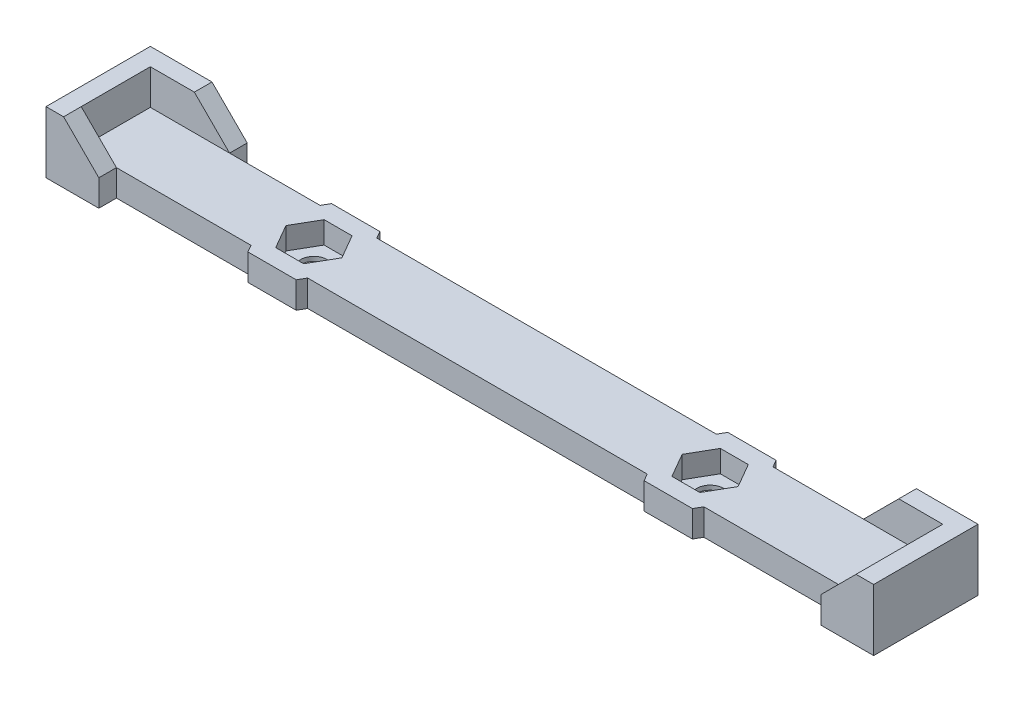
from build123d import *

# Parameters (mm, degrees)
SKETCH_1_W          = 90
SKETCH_1_H          = 7.85
EXTRUDE_1_DEPTH     = 2
SKETCH_2_W          = 7.85
SKETCH_2_H          = 6
EXTRUDE_2_DEPTH     = 2
SKETCH_3_W          = 7.85
SKETCH_3_H          = 6
EXTRUDE_3_DEPTH     = 2
EXTRUDE_4_DEPTH     = 2
EXTRUDE_5_DEPTH     = 2
EXTRUDE_8_DEPTH     = 1
CUT_EXTRUDE_1_DEPTH = 2.5
EXTRUDE_9_DEPTH     = 3
SKETCH_15_R         = 1.5
CUT_EXTRUDE_2_DEPTH = 3
SKETCH_16_R         = 1.5
CUT_EXTRUDE_3_DEPTH = 3


with BuildPart() as part:
    # 草图1 → 凸台-拉伸1 (new body)
    with BuildSketch(Plane(origin=(0, 0, 0), x_dir=(1, 0, 0), z_dir=(0, 1, 0))):
        with Locations((45, -3.925)):
            Rectangle(SKETCH_1_W, SKETCH_1_H)
    extrude(amount=EXTRUDE_1_DEPTH)

    # 草图2 → 凸台-拉伸2 (add)
    with BuildSketch(Plane(origin=(90, 0, 0), x_dir=(0, 0, -1), z_dir=(1, 0, 0))):
        with Locations((-3.925, 3)):
            Rectangle(SKETCH_2_W, SKETCH_2_H)
    extrude(amount=EXTRUDE_2_DEPTH)

    # 草图3 → 凸台-拉伸3 (add)
    with BuildSketch(Plane.ZY):
        with Locations((3.925, 3)):
            Rectangle(SKETCH_3_W, SKETCH_3_H)
    extrude(amount=EXTRUDE_3_DEPTH)

    # 草图4 → 凸台-拉伸4 (add)
    with BuildSketch(Plane(origin=(0, 0, 0), x_dir=(-1, 0, 0), z_dir=(0, 0, -1))):
        Polygon((2, 0), (2, 6), (0, 6), (-5, 6), (-9, 2), (-9, 0), align=None)
        Polygon((-92, 0), (-92, 6), (-90, 6), (-85, 6), (-81, 2), (-81, 0), align=None)
    extrude(amount=EXTRUDE_4_DEPTH)

    # 草图5 → 凸台-拉伸5 (add)
    with BuildSketch(Plane.XY.offset(7.85)):
        Polygon((92, 0), (92, 6), (90, 6), (86, 2), (86, 0), align=None)
        Polygon((-2, 0), (-2, 6), (0, 6), (4, 2), (4, 0), align=None)
    extrude(amount=EXTRUDE_5_DEPTH)

    # 草图10 → 凸台-拉伸8 (add)
    with BuildSketch(Plane.XZ):
        Polygon((-2, -2), (-2, 9.85), (4, 9.85), (4, 7.85), (86, 7.85), (86, 9.85), (92, 9.85), (92, -2), (81, -2), (81, 0), (9, 0), (9, -2), align=None)
    extrude(amount=EXTRUDE_8_DEPTH)

    # 草图12 → 切除-拉伸1 (cut)
    with BuildSketch(Plane(origin=(0, 2, 0), x_dir=(1, 0, 0), z_dir=(0, 1, 0))):
        Polygon((25.675426481, -3.925), (24.08771324, -1.175), (20.91228676, -1.175), (19.324573519, -3.925), (20.91228676, -6.675), (24.08771324, -6.675), align=None)
        Polygon((70.675426481, -3.925), (69.08771324, -1.175), (65.91228676, -1.175), (64.324573519, -3.925), (65.91228676, -6.675), (69.08771324, -6.675), align=None)
    extrude(amount=-CUT_EXTRUDE_1_DEPTH, mode=Mode.SUBTRACT)

    # 草图13 → 凸台-拉伸9 (add)
    with BuildSketch(Plane(origin=(0, 2, 0), x_dir=(1, 0, 0), z_dir=(0, 1, 0))):
        Polygon((27.984827557, -3.925), (25.242413779, 0.825), (19.757586221, 0.825), (17.015172443, -3.925), (19.757586221, -8.675), (25.242413779, -8.675), align=None)
        Polygon((24.08771324, -6.675), (25.675426481, -3.925), (24.08771324, -1.175), (20.91228676, -1.175), (19.324573519, -3.925), (20.91228676, -6.675), align=None, mode=Mode.SUBTRACT)
        Polygon((72.984827557, -3.925), (70.242413779, 0.825), (64.757586221, 0.825), (62.015172443, -3.925), (64.757586221, -8.675), (70.242413779, -8.675), align=None)
        Polygon((69.08771324, -6.675), (70.675426481, -3.925), (69.08771324, -1.175), (65.91228676, -1.175), (64.324573519, -3.925), (65.91228676, -6.675), align=None, mode=Mode.SUBTRACT)
    extrude(amount=-EXTRUDE_9_DEPTH)

    # 草图15 → 切除-拉伸2 (cut)
    with BuildSketch(Plane(origin=(0, -0.5, 0), x_dir=(1, 0, 0), z_dir=(0, 1, 0))):
        with Locations((22.5, -3.925)):
            Circle(SKETCH_15_R)
    extrude(amount=-CUT_EXTRUDE_2_DEPTH, mode=Mode.SUBTRACT)

    # 草图16 → 切除-拉伸3 (cut)
    with BuildSketch(Plane(origin=(0, -0.5, 0), x_dir=(1, 0, 0), z_dir=(0, 1, 0))):
        with Locations((67.5, -3.925)):
            Circle(SKETCH_16_R)
    extrude(amount=-CUT_EXTRUDE_3_DEPTH, mode=Mode.SUBTRACT)


solid = part.part
